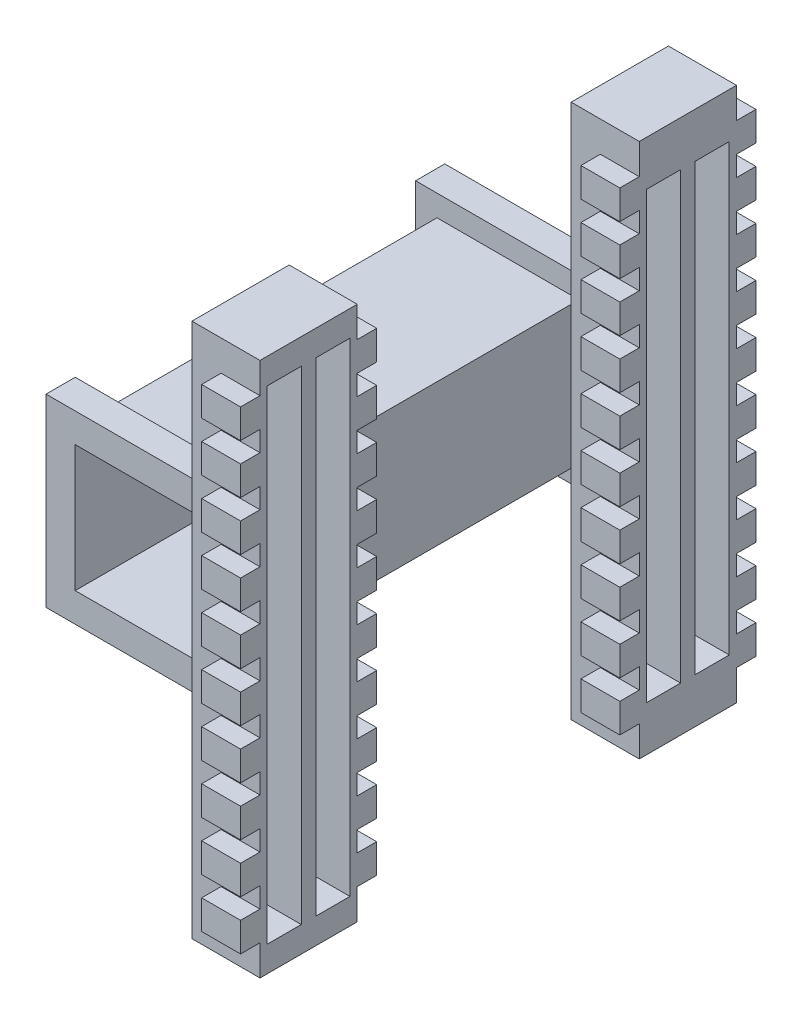
from build123d import *

# Parameters (mm, degrees)
SKETCH_1_W          = 14.6
SKETCH_1_H          = 14.6
SKETCH_1_W_2        = 13
SKETCH_1_H_2        = 13
EXTRUDE_4_DEPTH     = 20.5
SKETCH_1_12_W       = 14.6
SKETCH_1_12_H       = 14.6
EXTRUDE_8_DEPTH     = 20.5
SKETCH_1_13_W       = 14.6
SKETCH_1_13_H       = 14.6
CUT_EXTRUDE_3_DEPTH = 17.5
EXTRUDE_9_DEPTH     = 26.5
CUT_EXTRUDE_4_DEPTH = 12.5
CUT_EXTRUDE_5_DEPTH = 2
CUT_EXTRUDE_6_DEPTH = 2
CUT_EXTRUDE_7_DEPTH = 2
CUT_EXTRUDE_8_DEPTH = 2
SKETCH_10_W         = 3.5
SKETCH_10_H         = 45.72
SKETCH_10_H_2       = 49.72
CUT_EXTRUDE_9_DEPTH = 4


with BuildPart() as part:
    # 草图1 → 凸台-拉伸4 (new, symmetric)
    with BuildSketch(Plane.XY):
        with Locations((7.3, 7.3)):
            Rectangle(SKETCH_1_W, SKETCH_1_H)
        with Locations((7.3, 7.3)):
            Rectangle(SKETCH_1_W_2, SKETCH_1_H_2, mode=Mode.SUBTRACT)
    extrude(amount=EXTRUDE_4_DEPTH, both=True)

    # 草图1<12> → 凸台-拉伸8 (add, symmetric)
    with BuildSketch(Plane.XY):
        Polygon((16.8, 7.3), (16.8, 14.6), (16.8, 16.8), (-2.2, 16.8), (-2.2, -2.2), (14.6, -2.2), (16.8, -2.2), (16.8, 0), align=None)
        with Locations((7.3, 7.3)):
            Rectangle(SKETCH_1_12_W, SKETCH_1_12_H, mode=Mode.SUBTRACT)
    extrude(amount=EXTRUDE_8_DEPTH, both=True)

    # 草图1<13> → 切除-拉伸3 (cut, symmetric)
    with BuildSketch(Plane.XY):
        Polygon((14.6, -2.2), (-2.2, -2.2), (-2.2, 16.8), (16.8, 16.8), (16.8, -2.2), align=None)
        with Locations((7.3, 7.3)):
            Rectangle(SKETCH_1_13_W, SKETCH_1_13_H, mode=Mode.SUBTRACT)
    extrude(amount=CUT_EXTRUDE_3_DEPTH, both=True, mode=Mode.SUBTRACT)

    # 草图1<14> → 凸台-拉伸9 (add, symmetric)
    with BuildSketch(Plane.XY):
        Polygon((16.8, 16.8), (16.8, 14.6), (16.8, 7.3), (16.8, 0), (16.8, -2.2), (16.8, -20.2), (23.8, -20.2), (23.8, 34.8), (16.8, 34.8), align=None)
    extrude(amount=EXTRUDE_9_DEPTH, both=True)

    # 草图1<15> → 切除-拉伸4 (cut, symmetric)
    with BuildSketch(Plane.XY):
        Polygon((16.8, 7.3), (16.8, 34.8), (23.8, 34.8), (23.8, -20.2), (16.8, -20.2), align=None)
    extrude(amount=CUT_EXTRUDE_4_DEPTH, both=True, mode=Mode.SUBTRACT)

    # 草图6 → 切除-拉伸5 (cut)
    with BuildSketch(Plane(origin=(0, 0, -26.5), x_dir=(-1, 0, 0), z_dir=(0, 0, -1))):
        Polygon((-23.8, 34.8), (-23.8, 31.66), (-19.8, 31.66), (-19.8, 28.66), (-23.8, 28.66), (-23.8, 26.58), (-19.8, 26.58), (-19.8, 23.58), (-23.8, 23.58), (-23.8, 21.5), (-19.8, 21.5), (-19.8, 18.5), (-23.8, 18.5), (-23.8, 16.42), (-19.8, 16.42), (-19.8, 13.42), (-23.8, 13.42), (-23.8, 11.34), (-19.8, 11.34), (-19.8, 8.34), (-23.8, 8.34), (-23.8, 6.26), (-19.8, 6.26), (-19.8, 3.26), (-23.8, 3.26), (-23.8, 1.186575338), (-19.8, 1.186575338), (-19.8, -1.826575338), (-23.8, -1.826575338), (-23.8, -3.9), (-19.8, -3.9), (-19.8, -6.9), (-23.8, -6.9), (-23.8, -8.98), (-19.8, -8.98), (-19.8, -11.98), (-23.8, -11.98), (-23.8, -14.06), (-19.8, -14.06), (-19.8, -17.06), (-23.8, -17.06), (-23.8, -20.2), (-16.8, -20.2), (-16.8, 34.8), align=None)
    extrude(amount=-CUT_EXTRUDE_5_DEPTH, mode=Mode.SUBTRACT)

    # 草图7 → 切除-拉伸6 (cut)
    with BuildSketch(Plane.XY.offset(-12.5)):
        Polygon((23.8, 31.66), (23.8, 34.8), (16.8, 34.8), (16.8, -20.2), (23.8, -20.2), (23.8, -17.06), (19.8, -17.06), (19.8, -14.06), (23.8, -14.06), (23.8, -11.98), (19.8, -11.98), (19.8, -8.98), (23.8, -8.98), (23.8, -6.9), (19.8, -6.9), (19.8, -3.9), (23.8, -3.9), (23.8, -1.826575338), (19.8, -1.826575338), (19.8, 1.186575338), (23.8, 1.186575338), (23.8, 3.26), (19.8, 3.26), (19.8, 6.26), (23.8, 6.26), (23.8, 8.34), (19.8, 8.34), (19.8, 11.34), (23.8, 11.34), (23.8, 13.42), (19.8, 13.42), (19.8, 16.42), (23.8, 16.42), (23.8, 18.5), (19.8, 18.5), (19.8, 21.5), (23.8, 21.5), (23.8, 23.58), (19.8, 23.58), (19.8, 26.58), (23.8, 26.58), (23.8, 28.66), (19.8, 28.66), (19.8, 31.66), align=None)
    extrude(amount=-CUT_EXTRUDE_6_DEPTH, mode=Mode.SUBTRACT)

    # 草图8 → 切除-拉伸7 (cut)
    with BuildSketch(Plane(origin=(0, 0, 12.5), x_dir=(-1, 0, 0), z_dir=(0, 0, -1))):
        Polygon((-16.8, -20.2), (-16.8, 34.8), (-23.8, 34.8), (-23.8, 31.66), (-19.8, 31.66), (-19.8, 28.66), (-23.8, 28.66), (-23.8, 26.58), (-19.8, 26.58), (-19.8, 23.58), (-23.8, 23.58), (-23.8, 21.5), (-19.8, 21.5), (-19.8, 18.5), (-23.8, 18.5), (-23.8, 16.42), (-19.8, 16.42), (-19.8, 13.42), (-23.8, 13.42), (-23.8, 11.34), (-19.8, 11.34), (-19.8, 8.34), (-23.8, 8.34), (-23.8, 6.26), (-19.8, 6.26), (-19.8, 3.26), (-23.8, 3.26), (-23.8, 1.186575338), (-19.8, 1.186575338), (-19.8, -1.826575338), (-23.8, -1.826575338), (-23.8, -3.9), (-19.8, -3.9), (-19.8, -6.9), (-23.8, -6.9), (-23.8, -8.98), (-19.8, -8.98), (-19.8, -11.98), (-23.8, -11.98), (-23.8, -14.06), (-19.8, -14.06), (-19.8, -17.06), (-23.8, -17.06), (-23.8, -20.2), align=None)
    extrude(amount=-CUT_EXTRUDE_7_DEPTH, mode=Mode.SUBTRACT)

    # 草图9 → 切除-拉伸8 (cut)
    with BuildSketch(Plane.XY.offset(26.5)):
        Polygon((16.8, 34.8), (16.8, -20.2), (23.8, -20.2), (23.8, -17.06), (19.8, -17.06), (19.8, -14.06), (23.8, -14.06), (23.8, -11.98), (19.8, -11.98), (19.8, -8.98), (23.8, -8.98), (23.8, -6.9), (19.8, -6.9), (19.8, -3.9), (23.8, -3.9), (23.8, -1.826575338), (19.8, -1.826575338), (19.8, 1.186575338), (23.8, 1.186575338), (23.8, 3.26), (19.8, 3.26), (19.8, 6.26), (23.8, 6.26), (23.8, 8.34), (19.8, 8.34), (19.8, 11.34), (23.8, 11.34), (23.8, 13.42), (19.8, 13.42), (19.8, 16.42), (23.8, 16.42), (23.8, 18.5), (19.8, 18.5), (19.8, 21.5), (23.8, 21.5), (23.8, 23.58), (19.8, 23.58), (19.8, 26.58), (23.8, 26.58), (23.8, 28.66), (19.8, 28.66), (19.8, 31.66), (23.8, 31.66), (23.8, 34.8), align=None)
    extrude(amount=-CUT_EXTRUDE_8_DEPTH, mode=Mode.SUBTRACT)

    # 草图10 → 切除-拉伸9 (cut)
    with BuildSketch(Plane(origin=(23.8, 0, 0), x_dir=(0, 0, -1), z_dir=(1, 0, 0))):
        with Locations((17, 7.3)):
            Rectangle(SKETCH_10_W, SKETCH_10_H)
        with Locations((22.004742075, 7.3)):
            Rectangle(SKETCH_10_W, SKETCH_10_H)
        with Locations((-22.004742075, 7.3)):
            Rectangle(SKETCH_10_W, SKETCH_10_H_2)
        with Locations((-17, 7.3)):
            Rectangle(SKETCH_10_W, SKETCH_10_H_2)
    extrude(amount=-CUT_EXTRUDE_9_DEPTH, mode=Mode.SUBTRACT)


solid = part.part
